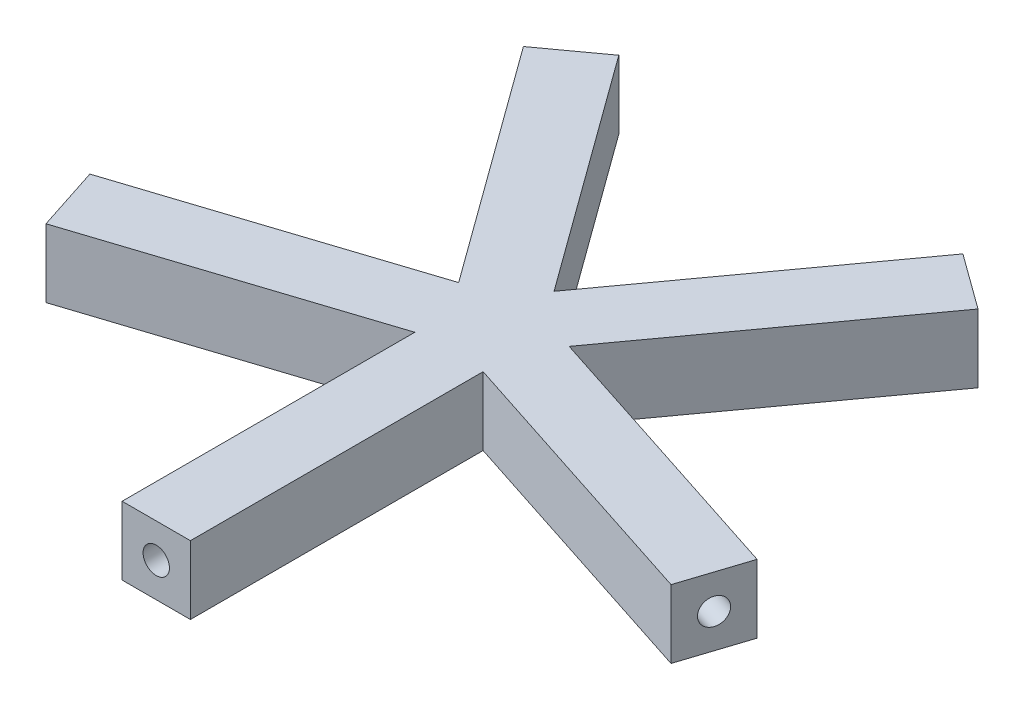
from build123d import *

# Parameters (mm, degrees)
BOSS_EXTRUDE1_DEPTH = 1.75
SKETCH2_R           = 0.675
CUT_EXTRUDE4_DEPTH  = 15
SKETCH7_R           = 0.675
CUT_EXTRUDE8_DEPTH  = 15
SKETCH8_R           = 0.675
CUT_EXTRUDE9_DEPTH  = 15
SKETCH9_R           = 0.675
CUT_EXTRUDE10_DEPTH = 15
SKETCH10_R          = 0.675
CUT_EXTRUDE11_DEPTH = 15


with BuildPart() as part:
    # Sketch1 → Boss-Extrude1 (new, symmetric)
    with BuildSketch(Plane(origin=(0, 0, 0), x_dir=(1, 0, 0), z_dir=(0, 1, 0))):
        Polygon((1.75, -2.408668361), (1.75, -17.408668361), (-1.75, -17.408668361), (-1.75, -2.408668361), (-16.015847744, -7.043923276), (-17.097407225, -3.715225469), (-2.83155948, 0.920029446), (-11.648338265, 13.055284362), (-8.816778784, 15.112532745), (0, 2.977277829), (8.816778784, 15.112532745), (11.648338265, 13.055284362), (2.83155948, 0.920029446), (17.097407225, -3.715225469), (16.015847744, -7.043923276), align=None)
    extrude(amount=BOSS_EXTRUDE1_DEPTH, both=True)

    # Sketch2 → Cut-Extrude4 (cut)
    with BuildSketch(Plane.XY.offset(17.408668361)):
        Circle(SKETCH2_R)
    extrude(amount=-CUT_EXTRUDE4_DEPTH, mode=Mode.SUBTRACT)

    # Sketch7 → Cut-Extrude8 (cut)
    with BuildSketch(Plane(origin=(16.556627485, 0, 5.379574373), x_dir=(0.3090169943749429, 0, -0.9510565162951551), z_dir=(0.9510565162951551, 0, 0.3090169943749429))):
        Circle(SKETCH7_R)
    extrude(amount=-CUT_EXTRUDE8_DEPTH, mode=Mode.SUBTRACT)

    # Sketch8 → Cut-Extrude9 (cut)
    with BuildSketch(Plane(origin=(10.232558525, 0, -14.083908553), x_dir=(-0.8090169943749378, 0, -0.5877852522924866), z_dir=(0.5877852522924866, 0, -0.8090169943749378))):
        Circle(SKETCH8_R)
    extrude(amount=-CUT_EXTRUDE9_DEPTH, mode=Mode.SUBTRACT)

    # Sketch9 → Cut-Extrude10 (cut)
    with BuildSketch(Plane(origin=(-10.232558525, 0, -14.083908553), x_dir=(-0.8090169943749476, 0, 0.5877852522924731), z_dir=(-0.587785252292473, 0, -0.8090169943749476))):
        Circle(SKETCH9_R)
    extrude(amount=-CUT_EXTRUDE10_DEPTH, mode=Mode.SUBTRACT)

    # Sketch10 → Cut-Extrude11 (cut)
    with BuildSketch(Plane(origin=(-16.556627485, 0, 5.379574373), x_dir=(0.3090169943749515, 0, 0.9510565162951523), z_dir=(-0.9510565162951523, 0, 0.3090169943749515))):
        Circle(SKETCH10_R)
    extrude(amount=-CUT_EXTRUDE11_DEPTH, mode=Mode.SUBTRACT)


solid = part.part
